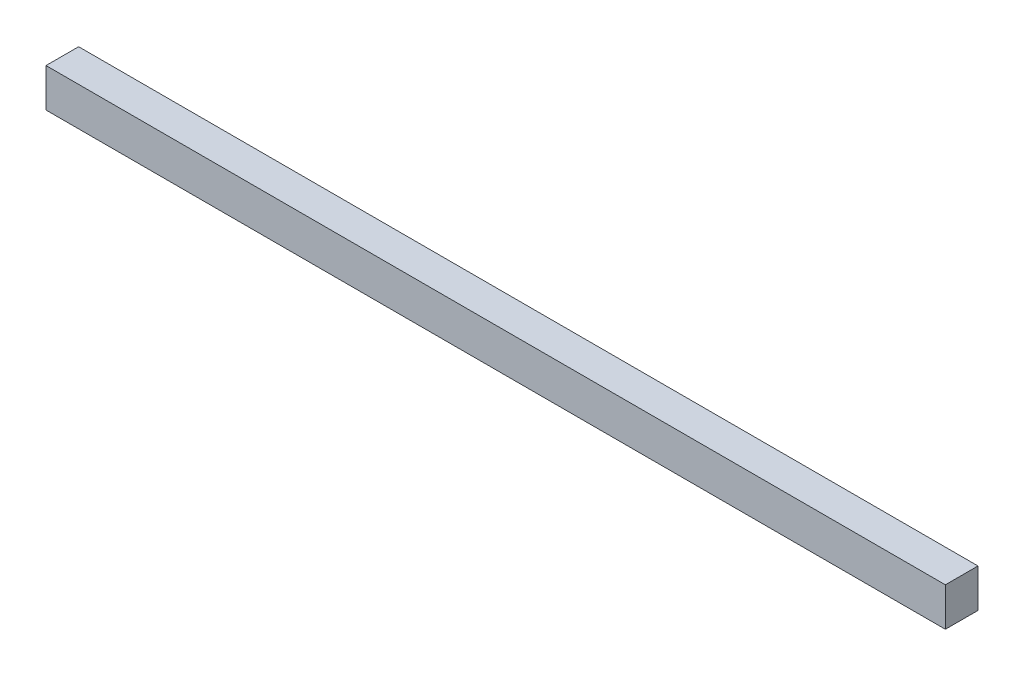
from build123d import *

# Parameters (mm, degrees)
SKETCH1_W      = 70
SKETCH1_H      = 3
EXTRUDE1_DEPTH = 2.54


with BuildPart() as part:
    # Sketch1 → Extrude1 (new body)
    with BuildSketch(Plane.XY):
        with Locations((35, -1.5)):
            Rectangle(SKETCH1_W, SKETCH1_H)
    extrude(amount=EXTRUDE1_DEPTH)


solid = part.part
